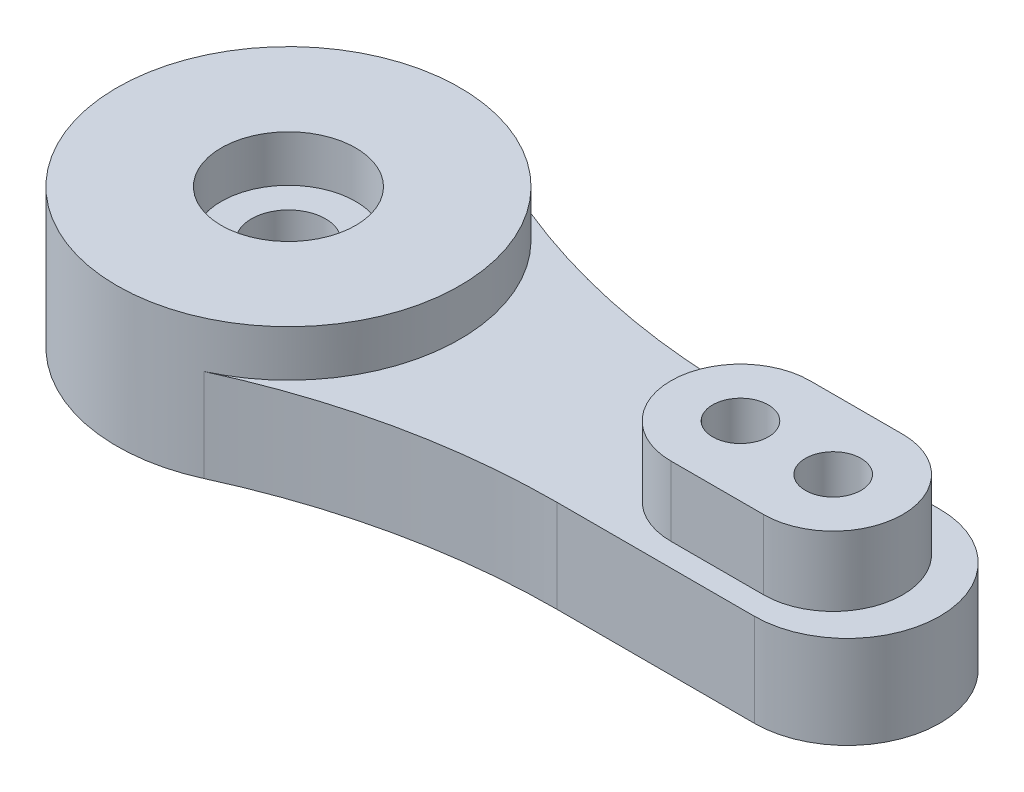
from build123d import *

# Parameters (mm, degrees)
SKETCH1_R           = 1.2
SKETCH1_R_2         = 1.6
BOSS_EXTRUDE1_DEPTH = 4
SKETCH2_R           = 1.2
BOSS_EXTRUDE2_DEPTH = 3
SKETCH3_R           = 2.9
BOSS_EXTRUDE3_DEPTH = 2


with BuildPart() as part:
    # Sketch1 → Boss-Extrude1 (new body)
    with BuildSketch(Plane(origin=(0, 0, 0), x_dir=(1, 0, 0), z_dir=(0, 1, 0))):
        with BuildLine():
            Line((24.1, 4), (15.580757363, 4))
            ThreePointArc((15.580757363, 4), (9.184735872, 4.689747372), (3.082823649, 6.727272727))
            ThreePointArc((3.082823649, 6.727272727), (-7.4, 0), (3.082823649, -6.727272727))
            ThreePointArc((3.082823649, -6.727272727), (9.184735872, -4.689747372), (15.580757363, -4))
            Line((15.580757363, -4), (24.1, -4))
            ThreePointArc((24.1, -4), (28.1, 0), (24.1, 4))
        make_face()
        with Locations((19.5, 0)):
            Circle(SKETCH1_R, mode=Mode.SUBTRACT)
        with Locations((23.5, 0)):
            Circle(SKETCH1_R, mode=Mode.SUBTRACT)
        Circle(SKETCH1_R_2, mode=Mode.SUBTRACT)
    extrude(amount=BOSS_EXTRUDE1_DEPTH)

    # Sketch2 → Boss-Extrude2 (add)
    with BuildSketch(Plane(origin=(0, 4, 0), x_dir=(1, 0, 0), z_dir=(0, 1, 0))):
        with BuildLine():
            Line((19.5, 3), (23.5, 3))
            ThreePointArc((23.5, 3), (26.5, 0), (23.5, -3))
            Line((23.5, -3), (19.5, -3))
            ThreePointArc((19.5, -3), (16.5, 0), (19.5, 3))
        make_face()
        with Locations((19.5, 0)):
            Circle(SKETCH2_R, mode=Mode.SUBTRACT)
        with Locations((23.5, 0)):
            Circle(SKETCH2_R, mode=Mode.SUBTRACT)
    extrude(amount=BOSS_EXTRUDE2_DEPTH)

    # Sketch3 → Boss-Extrude3 (add)
    with BuildSketch(Plane(origin=(0, 4, 0), x_dir=(1, 0, 0), z_dir=(0, 1, 0))):
        with BuildLine():
            ThreePointArc((7.4, 0), (6.227876645, 3.996692695), (3.082823649, 6.727272727))
            ThreePointArc((3.082823649, 6.727272727), (-7.4, 0), (3.082823649, -6.727272727))
            ThreePointArc((3.082823649, -6.727272727), (6.227876645, -3.996692695), (7.4, 0))
        make_face()
        Circle(SKETCH3_R, mode=Mode.SUBTRACT)
    extrude(amount=BOSS_EXTRUDE3_DEPTH)


solid = part.part
